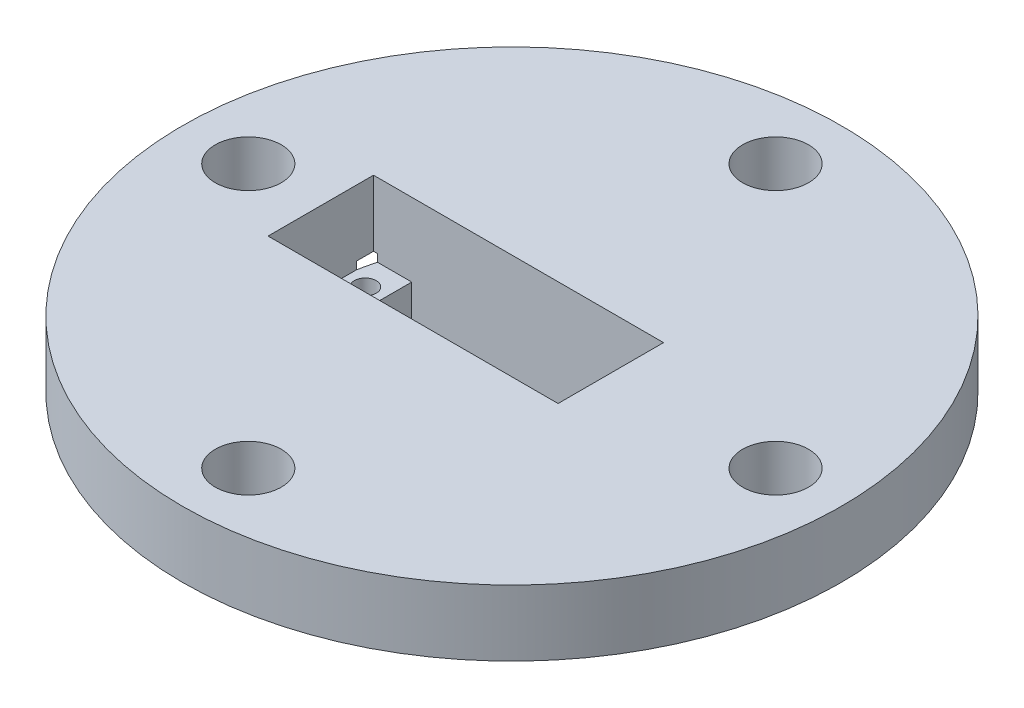
from build123d import *

# Parameters (mm, degrees)
SKETCH2_R           = 63.5
BOSS_EXTRUDE1_DEPTH = 12.7
SKETCH3_R           = 6.35
CUT_EXTRUDE1_DEPTH  = 13.7
SKETCH6_W           = 55.88
SKETCH6_H           = 20.32
CUT_EXTRUDE3_DEPTH  = 27.686
SKETCH8_W           = 60.96
SKETCH8_H           = 35.56
SKETCH8_W_2         = 55.88
SKETCH8_H_2         = 20.32
BOSS_EXTRUDE2_DEPTH = 1.45
SKETCH9_W           = 60.96
SKETCH9_H           = 35.56
SKETCH9_R           = 2.105780523
SKETCH9_W_2         = 41.148
SKETCH9_H_2         = 20.32
BOSS_EXTRUDE3_DEPTH = 10.16
SKETCH11_R          = 63.5
SKETCH11_R_2        = 37.465
CUT_EXTRUDE5_DEPTH  = 12.61


with BuildPart() as part:
    # Sketch2 → Boss-Extrude1 (new body)
    with BuildSketch(Plane(origin=(0, 0, 0), x_dir=(1, 0, 0), z_dir=(0, 1, 0))):
        Circle(SKETCH2_R)
    extrude(amount=BOSS_EXTRUDE1_DEPTH)

    # Sketch3 → Cut-Extrude1 (cut, through all)
    with BuildSketch(Plane.XZ):
        with Locations((0, 50.8)):
            Circle(SKETCH3_R)
        with Locations((-50.8, 0)):
            Circle(SKETCH3_R)
        with Locations((0, -50.8)):
            Circle(SKETCH3_R)
        with Locations((50.8, 0)):
            Circle(SKETCH3_R)
    extrude(amount=-CUT_EXTRUDE1_DEPTH, mode=Mode.SUBTRACT)

    # Sketch6 → Cut-Extrude3 (cut)
    with BuildSketch(Plane.XZ):
        with Locations((-8.89, 0)):
            Rectangle(SKETCH6_W, SKETCH6_H)
    extrude(amount=-CUT_EXTRUDE3_DEPTH, mode=Mode.SUBTRACT)

    # Sketch8 → Boss-Extrude2 (add)
    with BuildSketch(Plane.XZ):
        with Locations((-8.89, 0)):
            Rectangle(SKETCH8_W, SKETCH8_H)
        with Locations((-8.89, 0)):
            Rectangle(SKETCH8_W_2, SKETCH8_H_2, mode=Mode.SUBTRACT)
    extrude(amount=BOSS_EXTRUDE2_DEPTH)

    # Sketch9 → Boss-Extrude3 (add)
    with BuildSketch(Plane.XZ.offset(1.45)):
        with Locations((-8.89, 0)):
            Rectangle(SKETCH9_W, SKETCH9_H)
        with Locations((-33.125, 4.875)):
            Circle(SKETCH9_R, mode=Mode.SUBTRACT)
        with Locations((-33.125, -4.875)):
            Circle(SKETCH9_R, mode=Mode.SUBTRACT)
        with Locations((15.475, 4.875)):
            Circle(SKETCH9_R, mode=Mode.SUBTRACT)
        with Locations((15.475, -4.875)):
            Circle(SKETCH9_R, mode=Mode.SUBTRACT)
        with Locations((-8.89, 0)):
            Rectangle(SKETCH9_W_2, SKETCH9_H_2, mode=Mode.SUBTRACT)
    extrude(amount=BOSS_EXTRUDE3_DEPTH)

    # Sketch11 → Cut-Extrude5 (cut, through all)
    with BuildSketch(Plane.XZ):
        Circle(SKETCH11_R)
        Circle(SKETCH11_R_2, mode=Mode.SUBTRACT)
    extrude(amount=CUT_EXTRUDE5_DEPTH, mode=Mode.SUBTRACT)


solid = part.part
